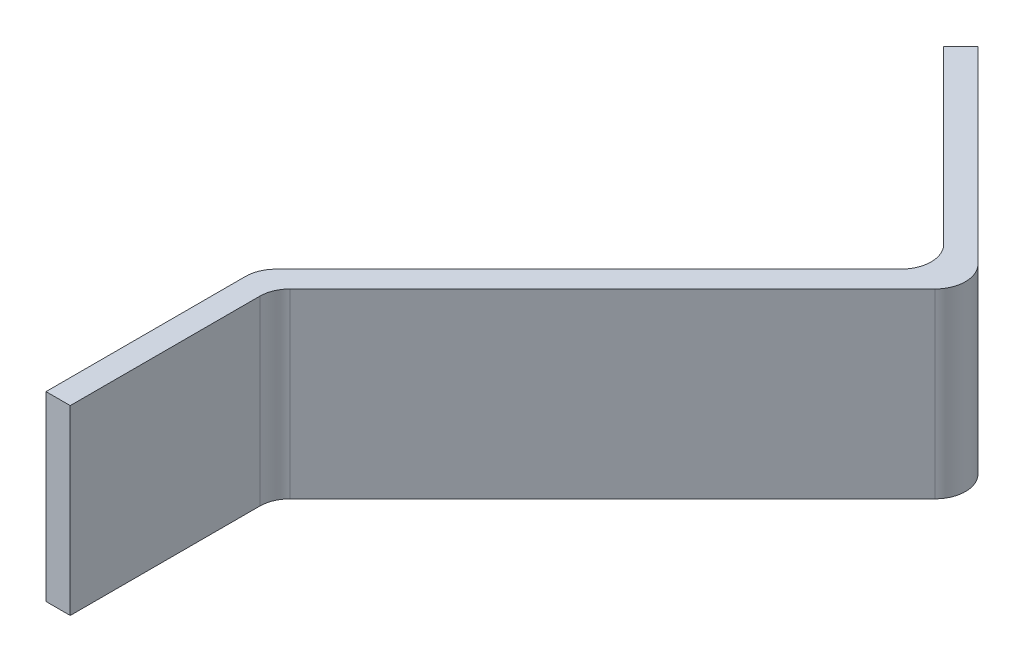
from build123d import *

# Parameters (mm, degrees)
BOSS_EXTRUDE1_DEPTH = 30


with BuildPart() as part:
    # Sketch1 → Boss-Extrude1 (new body)
    with BuildSketch(Plane(origin=(0, 7.5, 0), x_dir=(1, 0, 0), z_dir=(0, 1, 0))):
        with BuildLine():
            Line((248.792121733, 471.76093065), (217.679423361, 502.873629023))
            Line((217.679423361, 502.873629023), (214.850996236, 500.045201898))
            Line((214.850996236, 500.045201898), (243.135267484, 471.76093065))
            ThreePointArc((243.135267484, 471.76093065), (244.599733578, 468.225396744), (243.135267484, 464.689862838))
            Line((243.135267484, 464.689862838), (191.566724989, 413.121320344))
            ThreePointArc((191.566724989, 413.121320344), (190.482861232, 411.499203599), (190.102258895, 409.585786438))
            Line((190.102258895, 409.585786438), (190.102258895, 376.656854249))
            Line((190.102258895, 376.656854249), (194.102258895, 376.656854249))
            Line((194.102258895, 376.656854249), (194.102258895, 407.928932188))
            ThreePointArc((194.102258895, 407.928932188), (194.482861232, 409.84234935), (195.566724989, 411.464466094))
            Line((195.566724989, 411.464466094), (248.792121733, 464.689862838))
            ThreePointArc((248.792121733, 464.689862838), (250.256587827, 468.225396744), (248.792121733, 471.76093065))
        make_face()
    extrude(amount=-BOSS_EXTRUDE1_DEPTH)


solid = part.part
